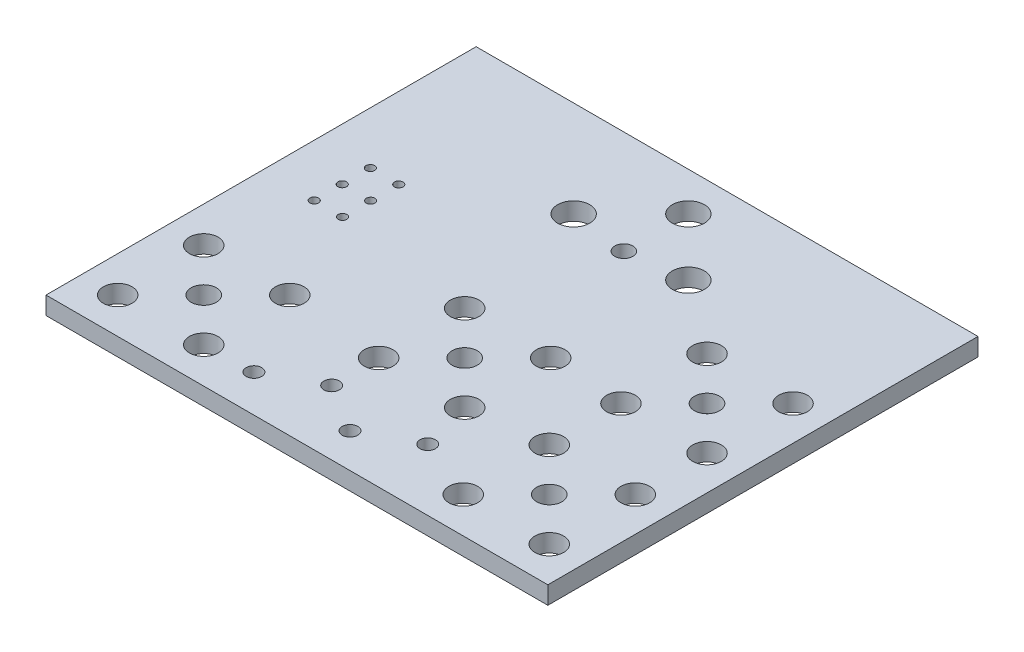
from build123d import *

# Parameters (mm, degrees)
SKETCH1_W                      = 44.45
SKETCH1_H                      = 38.1
SKETCH1_R                      = 1.1176
SKETCH1_R_2                    = 0.6858
SKETCH1_R_3                    = 1.27
BOSS_EXTRUDE1_DEPTH            = 1.5748
SKETCH2_R                      = 0.8001
SKETCH2_R_2                    = 0.381
SKETCH2_R_3                    = 1.4224
SWITCH_AND_R_A_CONNECTOR_DEPTH = 1.5748


with BuildPart() as part:
    # Sketch1 → Boss-Extrude1 (new body)
    with BuildSketch(Plane(origin=(0, 0, 0), x_dir=(1, 0, 0), z_dir=(0, 1, 0))):
        Rectangle(SKETCH1_W, SKETCH1_H)
        with Locations((-15.24, -12.065)):
            Circle(SKETCH1_R, mode=Mode.SUBTRACT)
        with Locations((1.651, -16.002)):
            Circle(SKETCH1_R_2, mode=Mode.SUBTRACT)
        with Locations((-7.112, -15.748)):
            Circle(SKETCH1_R_2, mode=Mode.SUBTRACT)
        with Locations((-11.43, -8.255)):
            Circle(SKETCH1_R_3, mode=Mode.SUBTRACT)
        with Locations((-11.43, -15.875)):
            Circle(SKETCH1_R_3, mode=Mode.SUBTRACT)
        with Locations((-19.05, -15.875)):
            Circle(SKETCH1_R_3, mode=Mode.SUBTRACT)
        with Locations((-19.05, -8.255)):
            Circle(SKETCH1_R_3, mode=Mode.SUBTRACT)
        with Locations((15.367, -12.065)):
            Circle(SKETCH1_R, mode=Mode.SUBTRACT)
        with Locations((19.177, -15.875)):
            Circle(SKETCH1_R_3, mode=Mode.SUBTRACT)
        with Locations((19.177, -8.255)):
            Circle(SKETCH1_R_3, mode=Mode.SUBTRACT)
        with Locations((11.557, -8.255)):
            Circle(SKETCH1_R_3, mode=Mode.SUBTRACT)
        with Locations((11.557, -15.875)):
            Circle(SKETCH1_R_3, mode=Mode.SUBTRACT)
        with Locations((1.143, -5.334)):
            Circle(SKETCH1_R, mode=Mode.SUBTRACT)
        with Locations((4.953, -9.144)):
            Circle(SKETCH1_R_3, mode=Mode.SUBTRACT)
        with Locations((4.953, -1.524)):
            Circle(SKETCH1_R_3, mode=Mode.SUBTRACT)
        with Locations((-2.667, -1.524)):
            Circle(SKETCH1_R_3, mode=Mode.SUBTRACT)
        with Locations((-2.667, -9.144)):
            Circle(SKETCH1_R_3, mode=Mode.SUBTRACT)
        with Locations((-2.64167216, -13.335)):
            Circle(SKETCH1_R_2, mode=Mode.SUBTRACT)
        with Locations((15.367, 1.905)):
            Circle(SKETCH1_R, mode=Mode.SUBTRACT)
        with Locations((11.557, -1.905)):
            Circle(SKETCH1_R_3, mode=Mode.SUBTRACT)
        with Locations((19.177, -1.905)):
            Circle(SKETCH1_R_3, mode=Mode.SUBTRACT)
        with Locations((19.177, 5.715)):
            Circle(SKETCH1_R_3, mode=Mode.SUBTRACT)
        with Locations((11.557, 5.715)):
            Circle(SKETCH1_R_3, mode=Mode.SUBTRACT)
        with Locations((6.12132784, -13.589)):
            Circle(SKETCH1_R_2, mode=Mode.SUBTRACT)
    extrude(amount=BOSS_EXTRUDE1_DEPTH)

    # Sketch2 → Switch and R A connector (cut)
    with BuildSketch(Plane(origin=(0, 1.5748, 0), x_dir=(1, 0, 0), z_dir=(0, 1, 0))):
        with Locations((0, 9.906)):
            Circle(SKETCH2_R)
        with Locations((-17.6022, 5.0546)):
            Circle(SKETCH2_R_2)
        with Locations((-17.6022, 2.5654)):
            Circle(SKETCH2_R_2)
        with Locations((-17.60295026, 0.083282904)):
            Circle(SKETCH2_R_2)
        with Locations((-15.0876, 5.0546)):
            Circle(SKETCH2_R_2)
        with Locations((-15.0876, 2.5654)):
            Circle(SKETCH2_R_2)
        with Locations((-15.0876, 0.0762)):
            Circle(SKETCH2_R_2)
        with Locations((-5.08, 10.541)):
            Circle(SKETCH2_R_3)
        with Locations((5.08, 10.541)):
            Circle(SKETCH2_R_3)
        with Locations((0, 15.621)):
            Circle(SKETCH2_R_3)
    extrude(amount=-SWITCH_AND_R_A_CONNECTOR_DEPTH, mode=Mode.SUBTRACT)


solid = part.part
